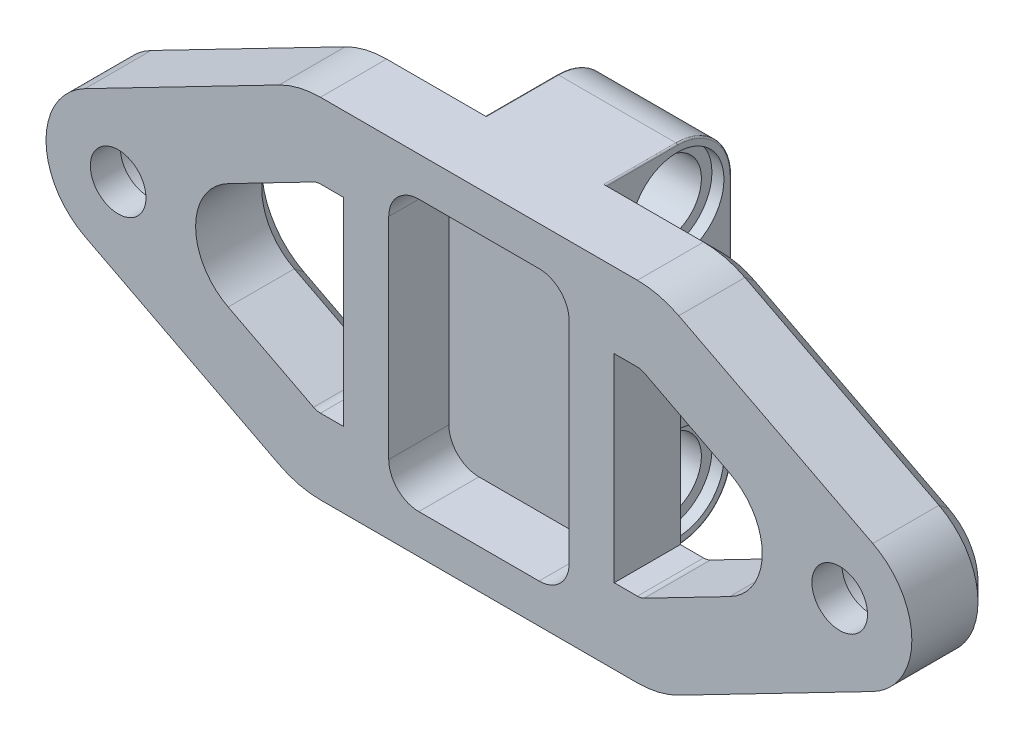
from build123d import *

# Parameters (mm, degrees)
SKETCH_2_R          = 1.85
EXTRUDE_1_DEPTH     = 5.6
SKETCH_3_R          = 2.95
CUT_EXTRUDE_1_DEPTH = 3.6
SKETCH_4_W          = 8
SKETCH_4_H          = 23.2
EXTRUDE_2_DEPTH     = 7.2
SKETCH_5_R          = 2.4
CUT_EXTRUDE_2_DEPTH = 33.8
FILLET_1_R          = 3.6
SKETCH_6_R          = 3.1
CUT_EXTRUDE_3_DEPTH = 0.8
FILLET_2_R          = 6
CUT_EXTRUDE_4_DEPTH = 6.6
CHAMFER_1_SIZE      = 1.2
SKETCH_8_W          = 12
SKETCH_8_H          = 18
CUT_EXTRUDE_5_DEPTH = 4
FILLET_3_R          = 2
FILLET_4_R          = 0.1
SKETCH_9_W          = 0.1
SKETCH_9_H          = 1.6
EXTRUDE_3_DEPTH     = 8


with BuildPart() as part:
    # ｽｹｯﾁ2 → ﾎﾞｽ - 押し出し1 (new body)
    with BuildSketch(Plane.XY):
        with BuildLine():
            Line((-12, 11.6), (-26.202629265, 4.264788895))
            ThreePointArc((-26.202629265, 4.264788895), (-28.8, 0), (-26.202629265, -4.264788895))
            Line((-26.202629265, -4.264788895), (-12, -11.6))
            Line((-12, -11.6), (12, -11.6))
            Line((12, -11.6), (26.202629265, -4.264788895))
            ThreePointArc((26.202629265, -4.264788895), (28.8, 0), (26.202629265, 4.264788895))
            Line((26.202629265, 4.264788895), (12, 11.6))
            Line((12, 11.6), (-12, 11.6))
        make_face()
        with Locations((-24, 0)):
            Circle(SKETCH_2_R, mode=Mode.SUBTRACT)
        with Locations((24, 0)):
            Circle(SKETCH_2_R, mode=Mode.SUBTRACT)
    extrude(amount=EXTRUDE_1_DEPTH)

    # ｽｹｯﾁ3 → ｶｯﾄ - 押し出し1 (cut)
    with BuildSketch(Plane(origin=(0, 0, 0), x_dir=(-1, 0, 0), z_dir=(0, 0, -1))):
        with Locations((-24, 0)):
            Circle(SKETCH_3_R)
        with Locations((24, 0)):
            Circle(SKETCH_3_R)
    extrude(amount=-CUT_EXTRUDE_1_DEPTH, mode=Mode.SUBTRACT)

    # ｽｹｯﾁ4 → ﾎﾞｽ - 押し出し2 (add)
    with BuildSketch(Plane(origin=(0, 0, 0), x_dir=(-1, 0, 0), z_dir=(0, 0, -1))):
        Rectangle(SKETCH_4_W, SKETCH_4_H)
    extrude(amount=EXTRUDE_2_DEPTH)

    # ｽｹｯﾁ5 → ｶｯﾄ - 押し出し2 (cut, through all)
    with BuildSketch(Plane(origin=(4, 0, 0), x_dir=(0, 0, -1), z_dir=(1, 0, 0))):
        with Locations((3.6, 8)):
            Circle(SKETCH_5_R)
        with Locations((3.6, -8)):
            Circle(SKETCH_5_R)
        with BuildLine():
            Line((2.8, 2.2627417), (2.8, 0.8))
            Line((2.8, 0.8), (1.3372583, 0.8))
            ThreePointArc((1.3372583, 0.8), (1.2, 0), (1.3372583, -0.8))
            Line((1.3372583, -0.8), (2.8, -0.8))
            Line((2.8, -0.8), (2.8, -2.2627417))
            ThreePointArc((2.8, -2.2627417), (3.6, -2.4), (4.4, -2.2627417))
            Line((4.4, -2.2627417), (4.4, -0.8))
            Line((4.4, -0.8), (5.8627417, -0.8))
            ThreePointArc((5.8627417, -0.8), (6, 0), (5.8627417, 0.8))
            Line((5.8627417, 0.8), (4.4, 0.8))
            Line((4.4, 0.8), (4.4, 2.2627417))
            ThreePointArc((4.4, 2.2627417), (3.6, 2.4), (2.8, 2.2627417))
        make_face()
    extrude(amount=-CUT_EXTRUDE_2_DEPTH, mode=Mode.SUBTRACT)

    # ﾌｨﾚｯﾄ1
    fillet_1_edges = [part.edges().sort_by_distance(p)[0] for p in [
        (0, -11.6, -7.2),
        (0, 11.6, -7.2),
    ]]
    fillet(fillet_1_edges, radius=FILLET_1_R)

    # ｽｹｯﾁ6 → ｶｯﾄ - 押し出し3 (cut)
    with BuildSketch(Plane(origin=(4, 0, 0), x_dir=(0, 0, -1), z_dir=(1, 0, 0))):
        with Locations((3.6, 8)):
            Circle(SKETCH_6_R)
        with Locations((3.6, -8)):
            Circle(SKETCH_6_R)
    cut_extrude_3 = extrude(amount=-CUT_EXTRUDE_3_DEPTH, mode=Mode.SUBTRACT)

    # ﾐﾗｰ1: ｶｯﾄ - 押し出し3 across plane
    add(cut_extrude_3.mirror(Plane(origin=(0, 0, 0), x_dir=(0, 0, 1), z_dir=(1, 0, 0))), mode=Mode.SUBTRACT)

    # ﾌｨﾚｯﾄ2
    fillet_2_edges = [part.edges().sort_by_distance(p)[0] for p in [
        (12, 11.6, 2.8),
        (12, -11.6, 2.8),
        (-12, -11.6, 2.8),
        (-12, 11.6, 2.8),
    ]]
    fillet(fillet_2_edges, radius=FILLET_2_R)

    # ｽｹｯﾁ7 → ｶｯﾄ - 押し出し4 (cut, through all)
    with BuildSketch(Plane(origin=(0, 0, 0), x_dir=(-1, 0, 0), z_dir=(0, 0, -1))):
        with BuildLine():
            Line((-16.682826602, -3.553990746), (-11.000956842, -6.488497686))
            ThreePointArc((-11.000956842, -6.488497686), (-10.778192574, -6.571724675), (-10.542075746, -6.6))
            Line((-10.542075746, -6.6), (-9, -6.6))
            Line((-9, -6.6), (-9, 6.6))
            Line((-9, 6.6), (-10.542075746, 6.6))
            ThreePointArc((-10.542075746, 6.6), (-10.778192574, 6.571724675), (-11.000956842, 6.488497686))
            Line((-11.000956842, 6.488497686), (-16.682826602, 3.553990746))
            ThreePointArc((-16.682826602, 3.553990746), (-18.847302214, 0), (-16.682826602, -3.553990746))
        make_face()
    cut_extrude_4 = extrude(amount=-CUT_EXTRUDE_4_DEPTH, mode=Mode.SUBTRACT)

    # ﾐﾗｰ2: ｶｯﾄ - 押し出し4 across plane
    add(cut_extrude_4.mirror(Plane(origin=(0, 0, 0), x_dir=(0, 0, 1), z_dir=(1, 0, 0))), mode=Mode.SUBTRACT)

    # 面取り1
    chamfer_1_edges = [part.edges().sort_by_distance(p)[0] for p in [
        (-19.748995796, -7.597887507, 0),
        (-28.8, 0, 0),
        (-7.271037873, -11.6, 0),
        (-19.748995796, 7.597887507, 0),
        (-11.958776717, 11.430348048, 0),
        (-11.958776717, -11.430348048, 0),
        (19.748995796, -7.597887507, 0),
        (7.271037873, 11.6, 0),
        (11.958776717, 11.430348048, 0),
        (11.958776717, -11.430348048, 0),
        (18.847302214, 0, 0),
        (13.841891722, -5.021244216, 0),
        (10.778192574, -6.571724675, 0),
        (9.771037873, -6.6, 0),
        (9, 0, 0),
        (9.771037873, 6.6, 0),
        (10.778192574, 6.571724675, 0),
        (13.841891722, 5.021244216, 0),
        (-18.847302214, 0, 0),
        (-13.841891722, -5.021244216, 0),
        (-10.778192574, -6.571724675, 0),
        (-9.771037873, -6.6, 0),
        (-9, 0, 0),
        (-9.771037873, 6.6, 0),
        (-10.778192574, 6.571724675, 0),
        (-13.841891722, 5.021244216, 0),
        (-7.271037873, 11.6, 0),
        (7.271037873, -11.6, 0),
        (19.748995796, 7.597887507, 0),
        (28.8, 0, 0),
    ]]
    chamfer(chamfer_1_edges, length=CHAMFER_1_SIZE)

    # ｽｹｯﾁ8 → ｶｯﾄ - 押し出し5 (cut)
    with BuildSketch(Plane.XY.offset(5.6)):
        Rectangle(SKETCH_8_W, SKETCH_8_H)
    extrude(amount=-CUT_EXTRUDE_5_DEPTH, mode=Mode.SUBTRACT)

    # ﾌｨﾚｯﾄ3
    fillet_3_edges = [part.edges().sort_by_distance(p)[0] for p in [
        (-6, -9, 3.6),
        (-6, 9, 3.6),
        (6, 9, 3.6),
        (6, -9, 3.6),
    ]]
    fillet(fillet_3_edges, radius=FILLET_3_R)

    # ﾌｨﾚｯﾄ4
    fillet_4_edges = [part.edges().sort_by_distance(p)[0] for p in [
        (4, 0, -7.2),
        (-4, 0, -7.2),
        (-4, 11.6, -1.2),
        (-4, -11.6, -1.2),
        (-4, 10.545584412, -6.145584412),
        (-4, -10.545584412, -6.145584412),
        (4, -11.6, -1.2),
        (4, 11.6, -1.2),
        (4, 10.545584412, -6.145584412),
        (4, -10.545584412, -6.145584412),
    ]]
    fillet(fillet_4_edges, radius=FILLET_4_R)


with BuildPart() as body_2:
    # ｽｹｯﾁ9 → ﾎﾞｽ - 押し出し3 (new body)
    with BuildSketch(Plane(origin=(4, 0, 0), x_dir=(0, 0, -1), z_dir=(1, 0, 0))):
        with Locations((4.45, 0)):
            Rectangle(SKETCH_9_W, SKETCH_9_H)
    extrude(amount=-EXTRUDE_3_DEPTH)


solid = Compound([part.part, body_2.part])
